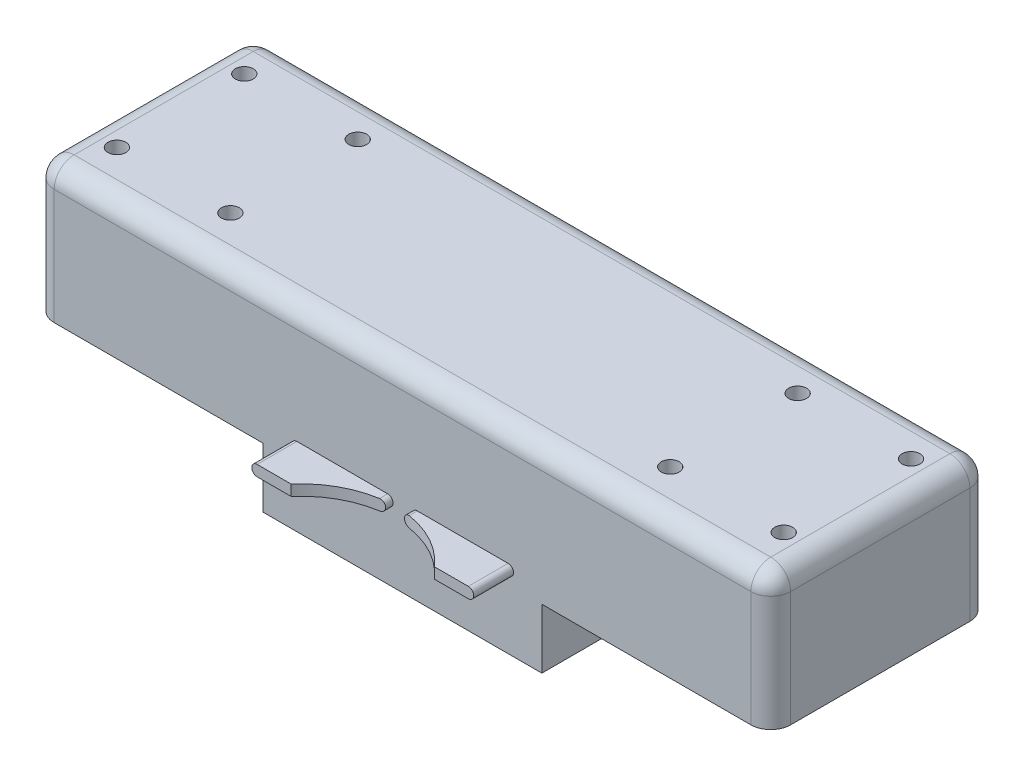
from build123d import *

# Parameters (mm, degrees)
BOSS_EXTRUDE1_DEPTH           = 55
BOSS_EXTRUDE4_DEPTH           = 10
BOSS_EXTRUDE3_DEPTH           = 5
CSK_FOR_M4_SFHCS2_D           = 4.5
CSK_FOR_M4_SFHCS2_CSINK_D     = 8.96
CSK_FOR_M4_SFHCS2_CSINK_ANGLE = 90
FILLET4_R                     = 5
SKETCH12_R                    = 23.75
CUT_EXTRUDE2_DEPTH            = 33.05


with BuildPart() as part:
    # Sketch2 → Boss-Extrude1 (new body)
    with BuildSketch(Plane.XY):
        Polygon((-92.5, 34), (92.5, 34), (92.5, 0), (35, 0), (35, -15), (-35, -15), (-35, 0), (-92.5, 0), align=None)
    extrude(amount=BOSS_EXTRUDE1_DEPTH)

    # Sketch4 → Boss-Extrude4 (add)
    with BuildSketch(Plane.XY.offset(55)):
        with BuildLine():
            Line((-26.525, 4.65), (-3.725, 4.65))
            ThreePointArc((-3.725, 4.65), (-2.375, 3.3), (-3.725, 1.95))
            Line((-3.725, 1.95), (-26.525, 1.95))
            ThreePointArc((-26.525, 1.95), (-27.875, 3.3), (-26.525, 4.65))
        make_face()
        with BuildLine():
            Line((26.525, 1.95), (3.725, 1.95))
            ThreePointArc((3.725, 1.95), (2.375, 3.3), (3.725, 4.65))
            Line((3.725, 4.65), (26.525, 4.65))
            ThreePointArc((26.525, 4.65), (27.875, 3.3), (26.525, 1.95))
        make_face()
    extrude(amount=BOSS_EXTRUDE4_DEPTH)

    # Sketch6 → Boss-Extrude3 (add)
    with BuildSketch(Plane(origin=(0, 0, 0), x_dir=(-1, 0, 0), z_dir=(0, 0, -1))):
        with BuildLine():
            Line((-11.45, 25.475), (11.45, 25.475))
            ThreePointArc((11.45, 25.475), (12.75, 24.175), (11.45, 22.875))
            Line((11.45, 22.875), (-11.45, 22.875))
            ThreePointArc((-11.45, 22.875), (-12.75, 24.175), (-11.45, 25.475))
        make_face()
        with BuildLine():
            Line((16.8, 25.475), (42.2, 25.475))
            ThreePointArc((42.2, 25.475), (43.5, 24.175), (42.2, 22.875))
            Line((42.2, 22.875), (16.8, 22.875))
            ThreePointArc((16.8, 22.875), (15.5, 24.175), (16.8, 25.475))
        make_face()
        with BuildLine():
            Line((-16.8, 22.875), (-42.2, 22.875))
            ThreePointArc((-42.2, 22.875), (-43.5, 24.175), (-42.2, 25.475))
            Line((-42.2, 25.475), (-16.8, 25.475))
            ThreePointArc((-16.8, 25.475), (-15.5, 24.175), (-16.8, 22.875))
        make_face()
        with BuildLine():
            Line((-32.2, 7), (32.2, 7))
            ThreePointArc((32.2, 7), (35, 4.2), (32.2, 1.4))
            Line((32.2, 1.4), (-32.2, 1.4))
            ThreePointArc((-32.2, 1.4), (-35, 4.2), (-32.2, 7))
        make_face()
    extrude(amount=BOSS_EXTRUDE3_DEPTH)

    # CSK for M4 SFHCS2 (through all)
    with Locations(Plane.XZ):
        with Locations((-83.75, 11), (-83.75, 43), (-55.25, 43), (55.25, 43), (83.75, 43), (83.75, 11), (55.25, 11), (-55.25, 11)):
            CounterSinkHole(CSK_FOR_M4_SFHCS2_D / 2, CSK_FOR_M4_SFHCS2_CSINK_D / 2, counter_sink_angle=CSK_FOR_M4_SFHCS2_CSINK_ANGLE)

    # Fillet4
    fillet4_edges = [part.edges().sort_by_distance(p)[0] for p in [
        (-92.5, 34, 27.5),
        (92.5, 34, 27.5),
        (92.5, 17, 55),
        (0, 34, 55),
        (-92.5, 17, 55),
        (-92.5, 17, 0),
        (0, 34, 0),
        (92.5, 17, 0),
    ]]
    fillet(fillet4_edges, radius=FILLET4_R)

    # Sketch12 → Cut-Extrude2 (cut, through all)
    with BuildSketch(Plane.XZ.offset(-1.95)):
        with Locations((0, 80.5)):
            Circle(SKETCH12_R)
    extrude(amount=-CUT_EXTRUDE2_DEPTH, mode=Mode.SUBTRACT)


solid = part.part
